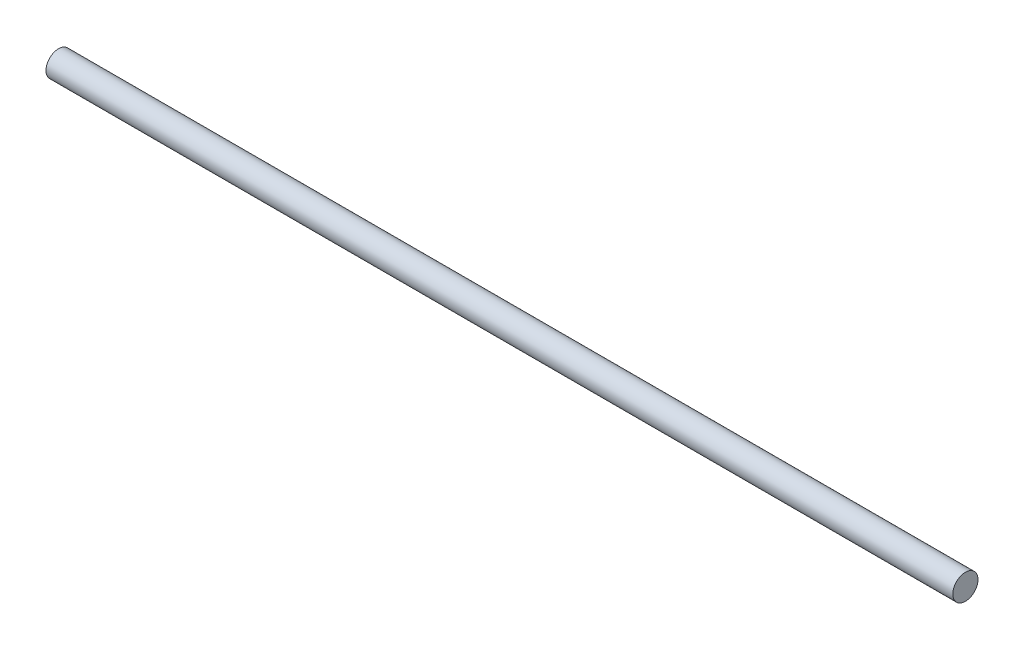
from build123d import *

# Parameters (mm, degrees)
SKETCH1_W = 900
SKETCH1_H = 12.5


with BuildPart() as part:
    # Sketch1 → Revolve1 (revolve)
    with BuildSketch(Plane(origin=(0, 0, 0), x_dir=(1, 0, 0), z_dir=(0, 1, 0))):
        with Locations((450, 6.25)):
            Rectangle(SKETCH1_W, SKETCH1_H)
    revolve(axis=Axis((0, 0, 0), (-1, 0, 0)))


solid = part.part
